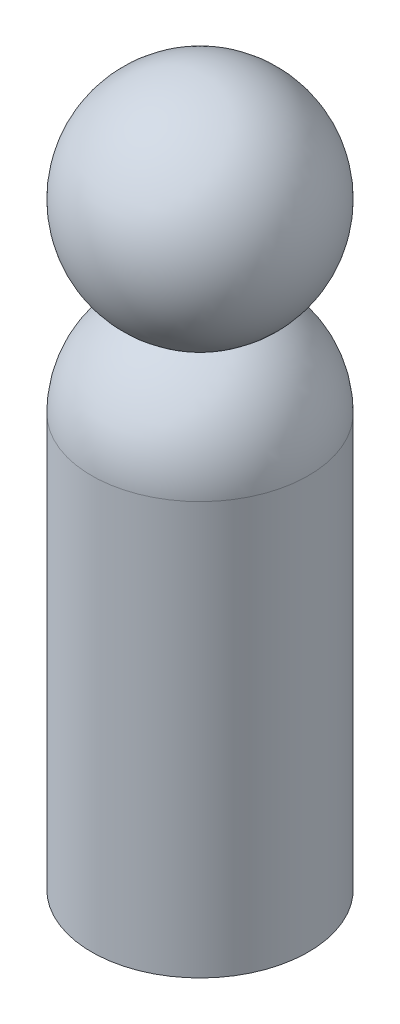
from build123d import *


with BuildPart() as part:
    # Sketch1 → Revolve1 (revolve)
    with BuildSketch(Plane.XY):
        with BuildLine():
            Line((0, 96.8375), (0, 0))
            Line((0, 0), (21.43125, 0))
            Line((21.43125, 0), (21.43125, 81.602620674))
            ThreePointArc((21.43125, 81.602620674), (18.494954345, 92.124465724), (10.534672909, 99.605439917))
            ThreePointArc((10.534672909, 99.605439917), (5.44611845, 97.541032557), (0, 96.8375))
        make_face()
        with BuildLine():
            Line((0, 139.7), (0, 96.8375))
            ThreePointArc((0, 96.8375), (5.44611845, 97.541032557), (10.534672909, 99.605439917))
            ThreePointArc((10.534672909, 99.605439917), (20.727717443, 123.71486845), (0, 139.7))
        make_face()
    revolve(axis=Axis((0, 0, 0), (0, 1, 0)))


solid = part.part
